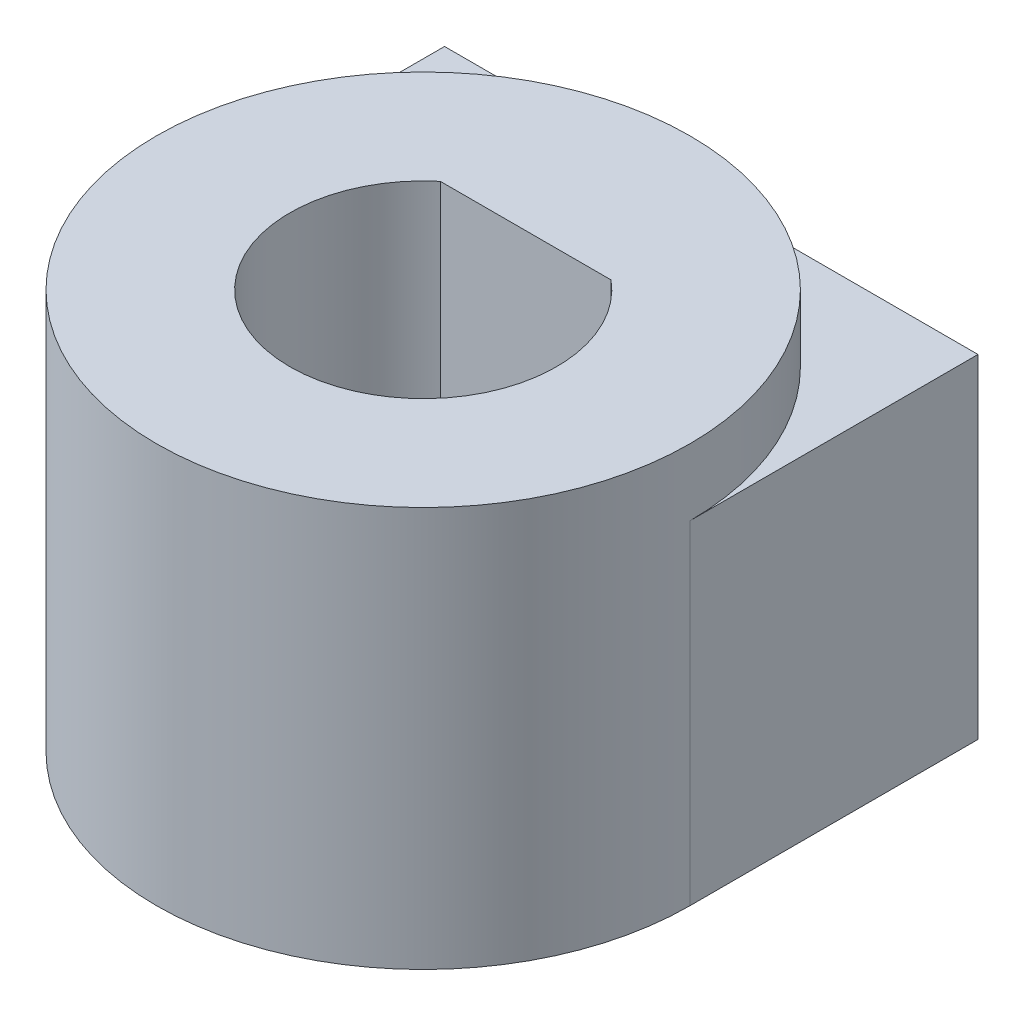
from build123d import *

# Parameters (mm, degrees)
BOSS_EXTRUDE1_DEPTH = 7.9375
SKETCH3_R           = 2.7559
CUT_EXTRUDE1_DEPTH  = 3.81
CUT_EXTRUDE2_REACH  = 11.398
SKETCH4_R           = 1.7526
SKETCH5_R           = 6.35
BOSS_EXTRUDE2_DEPTH = 1.5875


with BuildPart() as part:
    # Sketch1 → Boss-Extrude1 (new body)
    with BuildSketch(Plane(origin=(0, 0, 0), x_dir=(1, 0, 0), z_dir=(0, 1, 0))):
        with BuildLine():
            ThreePointArc((-6.35, 0), (0, -6.35), (6.35, 0))
            Line((6.35, 0), (6.35, 6.858))
            Line((6.35, 6.858), (-6.35, 6.858))
            Line((-6.35, 6.858), (-6.35, 0))
        make_face()
        with BuildLine():
            Line((-2.032, 2.439590334), (2.032, 2.439590334))
            ThreePointArc((2.032, 2.439590334), (0, -3.175), (-2.032, 2.439590334))
        make_face(mode=Mode.SUBTRACT)
    extrude(amount=BOSS_EXTRUDE1_DEPTH)

    # Sketch3 → Cut-Extrude1 (cut)
    with BuildSketch(Plane(origin=(0, 0, -6.858), x_dir=(-1, 0, 0), z_dir=(0, 0, -1))):
        with Locations((0, 3.96875)):
            Circle(SKETCH3_R)
    extrude(amount=-CUT_EXTRUDE1_DEPTH, mode=Mode.SUBTRACT)

    # Sketch4 → Cut-Extrude2 (cut, up to next)
    with BuildSketch(Plane(origin=(0, 0, -3.048), x_dir=(-1, 0, 0), z_dir=(0, 0, -1)), mode=Mode.PRIVATE) as cut_extrude2_sk1:
        with Locations((0, 3.96875)):
            Circle(SKETCH4_R)
    cut_extrude2_tool1 = extrude(cut_extrude2_sk1.sketch, amount=-CUT_EXTRUDE2_REACH, mode=Mode.PRIVATE) & part.part
    add(cut_extrude2_tool1.solids().sort_by_distance((0, 3.96875, -3.048))[0], mode=Mode.SUBTRACT)

    # Sketch5 → Boss-Extrude2 (add)
    with BuildSketch(Plane(origin=(0, 7.9375, 0), x_dir=(1, 0, 0), z_dir=(0, 1, 0))):
        Circle(SKETCH5_R)
        with BuildLine():
            Line((-2.032, 2.439590334), (2.032, 2.439590334))
            ThreePointArc((2.032, 2.439590334), (0, -3.175), (-2.032, 2.439590334))
        make_face(mode=Mode.SUBTRACT)
    extrude(amount=BOSS_EXTRUDE2_DEPTH)


solid = part.part
